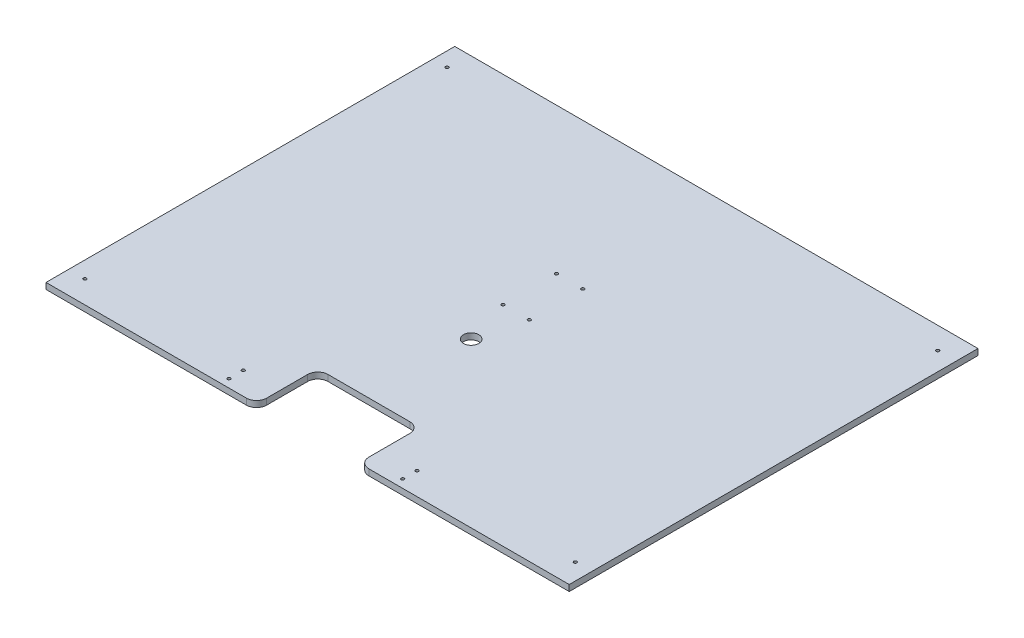
from build123d import *

# Parameters (mm, degrees)
SKETCH1_W           = 500
SKETCH1_H           = 400
SKETCH1_R           = 1.5
SKETCH1_R_2         = 1.525
BOSS_EXTRUDE1_DEPTH = 6
SKETCH2_R           = 1.5
CUT_EXTRUDE1_DEPTH  = 10
SKETCH3_W           = 50
SKETCH3_H           = 60
SKETCH3_R           = 7.5
CUT_EXTRUDE2_DEPTH  = 7
FILLET1_R           = 10
BOSS_EXTRUDE2_START = -6
SKETCH4_W           = 6
SKETCH4_H           = 400
BOSS_EXTRUDE2_DEPTH = 6


with BuildPart() as part:
    # Sketch1 → Boss-Extrude1 (new body)
    with BuildSketch(Plane(origin=(0, 0, 0), x_dir=(1, 0, 0), z_dir=(0, 1, 0))):
        with Locations((250, -200)):
            Rectangle(SKETCH1_W, SKETCH1_H)
        with Locations((490, -378)):
            Circle(SKETCH1_R, mode=Mode.SUBTRACT)
        with Locations((10, -378)):
            Circle(SKETCH1_R, mode=Mode.SUBTRACT)
        with Locations((236.4, -195.2)):
            Circle(SKETCH1_R, mode=Mode.SUBTRACT)
        with Locations((262.1, -195.2)):
            Circle(SKETCH1_R, mode=Mode.SUBTRACT)
        with Locations((262.1, -142.9)):
            Circle(SKETCH1_R, mode=Mode.SUBTRACT)
        with Locations((236.4, -142.9)):
            Circle(SKETCH1_R, mode=Mode.SUBTRACT)
        with Locations((8, -21.5)):
            Circle(SKETCH1_R, mode=Mode.SUBTRACT)
        with Locations((488, -21.5)):
            Circle(SKETCH1_R_2, mode=Mode.SUBTRACT)
    extrude(amount=BOSS_EXTRUDE1_DEPTH)

    # Sketch2 → Cut-Extrude1 (cut)
    with BuildSketch(Plane(origin=(0, 6, 0), x_dir=(1, 0, 0), z_dir=(0, 1, 0))):
        with Locations((165, -378)):
            Circle(SKETCH2_R)
        with Locations((165, -392)):
            Circle(SKETCH2_R)
        with Locations((335, -378)):
            Circle(SKETCH2_R)
        with Locations((335, -392)):
            Circle(SKETCH2_R)
    extrude(amount=-CUT_EXTRUDE1_DEPTH, mode=Mode.SUBTRACT)

    # Sketch3 → Cut-Extrude2 (cut, through all)
    with BuildSketch(Plane.XZ):
        with Locations((275, 370)):
            Rectangle(SKETCH3_W, SKETCH3_H)
        with Locations((225, 370)):
            Rectangle(SKETCH3_W, SKETCH3_H)
        with Locations((250, 240)):
            Circle(SKETCH3_R)
    extrude(amount=-CUT_EXTRUDE2_DEPTH, mode=Mode.SUBTRACT)

    # Fillet1
    fillet1_edges = [part.edges().sort_by_distance(p)[0] for p in [
        (300, 3, 340),
        (200, 3, 340),
        (200, 3, 400),
        (300, 3, 400),
    ]]
    fillet(fillet1_edges, radius=FILLET1_R)

    # Sketch4 → Boss-Extrude2 (add)
    with BuildSketch(Plane.XZ.offset(BOSS_EXTRUDE2_START)):
        with Locations((-3, 200)):
            Rectangle(SKETCH4_W, SKETCH4_H)
        with Locations((503, 200)):
            Rectangle(SKETCH4_W, SKETCH4_H)
    extrude(amount=BOSS_EXTRUDE2_DEPTH)


solid = part.part
